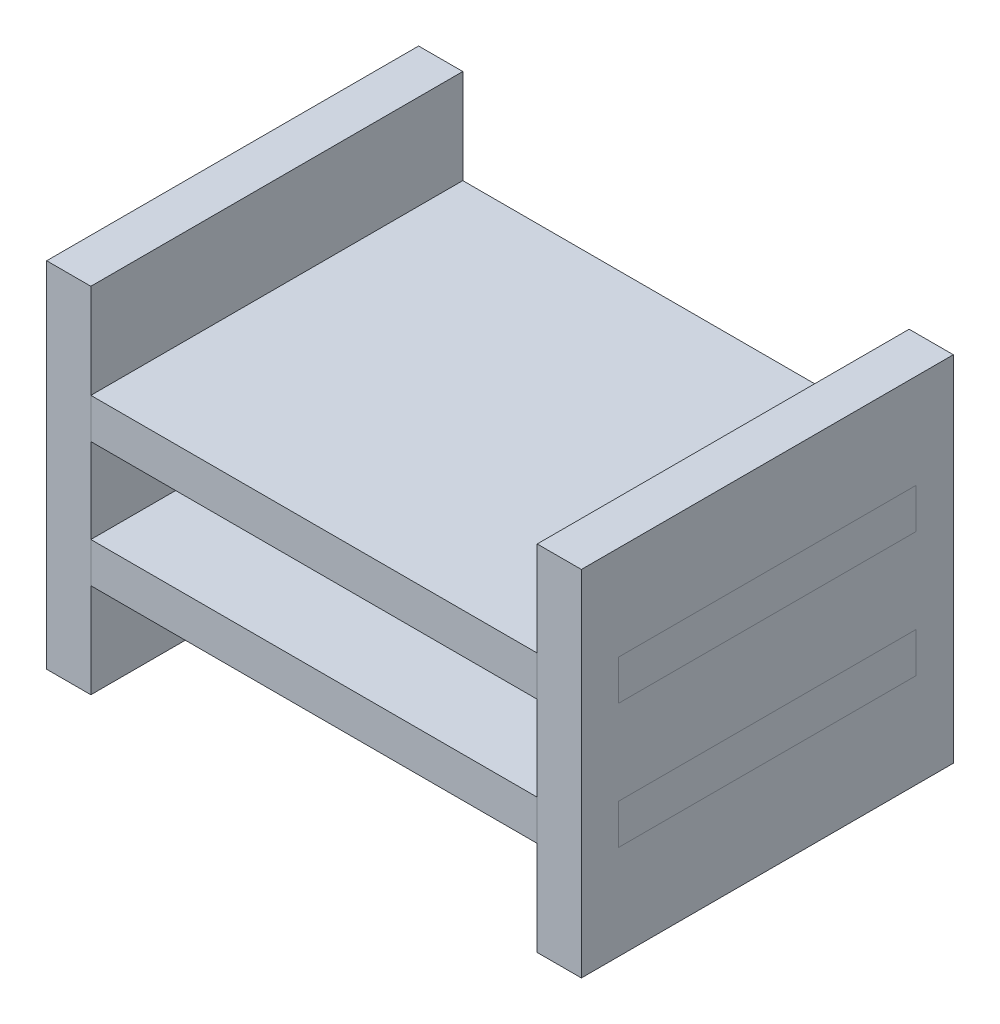
from build123d import *

# Parameters (mm, degrees)
SKETCH2_W           = 30
SKETCH2_H           = 25
SKETCH2_W_2         = 2.97
SKETCH2_H_2         = 20
BOSS_EXTRUDE3_DEPTH = 2.69
BOSS_EXTRUDE4_START = 8.39
SKETCH2_3_W         = 2.97
SKETCH2_3_H         = 20
SKETCH2_3_W_2       = 30
SKETCH2_3_H_2       = 25
BOSS_EXTRUDE4_DEPTH = 2.69
SKETCH4_W           = 25
SKETCH4_H           = 23.78
SKETCH4_W_2         = 20
SKETCH4_H_2         = 2.69
BOSS_EXTRUDE5_DEPTH = 2.97


with BuildPart() as part:
    # Sketch2 → Boss-Extrude3 (new body)
    with BuildSketch(Plane(origin=(0, 0, 0), x_dir=(1, 0, 0), z_dir=(0, 1, 0))):
        Rectangle(SKETCH2_W, SKETCH2_H)
        with Locations((-16.485, 0)):
            Rectangle(SKETCH2_W_2, SKETCH2_H_2)
        with Locations((16.485, 0)):
            Rectangle(SKETCH2_W_2, SKETCH2_H_2)
    extrude(amount=BOSS_EXTRUDE3_DEPTH)


with BuildPart() as body_2:
    # Sketch2_3 → Boss-Extrude4 (new body)
    with BuildSketch(Plane(origin=(0, 0, 0), x_dir=(1, 0, 0), z_dir=(0, 1, 0)).offset(BOSS_EXTRUDE4_START)):
        with Locations((-16.485, 0)):
            Rectangle(SKETCH2_3_W, SKETCH2_3_H)
        Rectangle(SKETCH2_3_W_2, SKETCH2_3_H_2)
        with Locations((16.485, 0)):
            Rectangle(SKETCH2_3_W, SKETCH2_3_H)
    extrude(amount=BOSS_EXTRUDE4_DEPTH)


with BuildPart() as body_3:
    # Sketch4 → Boss-Extrude5 (new body)
    with BuildSketch(Plane(origin=(15, 0, 0), x_dir=(0, 0, -1), z_dir=(1, 0, 0))):
        with Locations((0, 5.54)):
            Rectangle(SKETCH4_W, SKETCH4_H)
        with Locations((0, 9.735)):
            Rectangle(SKETCH4_W_2, SKETCH4_H_2, mode=Mode.SUBTRACT)
        with Locations((0, 1.345)):
            Rectangle(SKETCH4_W_2, SKETCH4_H_2, mode=Mode.SUBTRACT)
    extrude(amount=BOSS_EXTRUDE5_DEPTH)


with BuildPart() as body_4:
    # Mirror1: mirrored copy
    add(body_3.part.mirror(Plane(origin=(0, 0, 0), x_dir=(0, 0, 1), z_dir=(1, 0, 0))))


solid = Compound([part.part, body_2.part, body_3.part, body_4.part])
